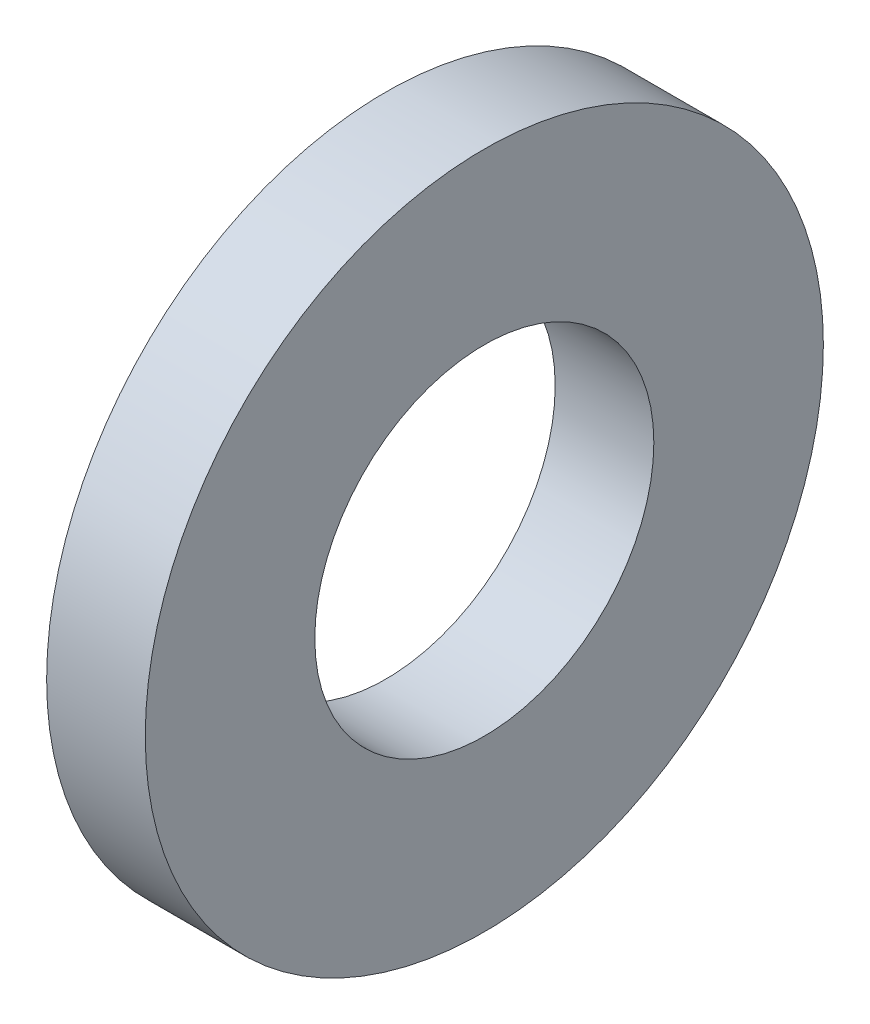
from build123d import *

# Parameters (mm, degrees)
SKETCH1_R          = 5.5
SKETCH1_R_2        = 2.75
BASE_EXTRUDE_DEPTH = 1.6


with BuildPart() as part:
    # Sketch1 → Base-Extrude (new body)
    with BuildSketch(Plane(origin=(0, 0, 0), x_dir=(0, 0, -1), z_dir=(1, 0, 0))):
        Circle(SKETCH1_R)
        Circle(SKETCH1_R_2, mode=Mode.SUBTRACT)
    extrude(amount=BASE_EXTRUDE_DEPTH)


solid = part.part
